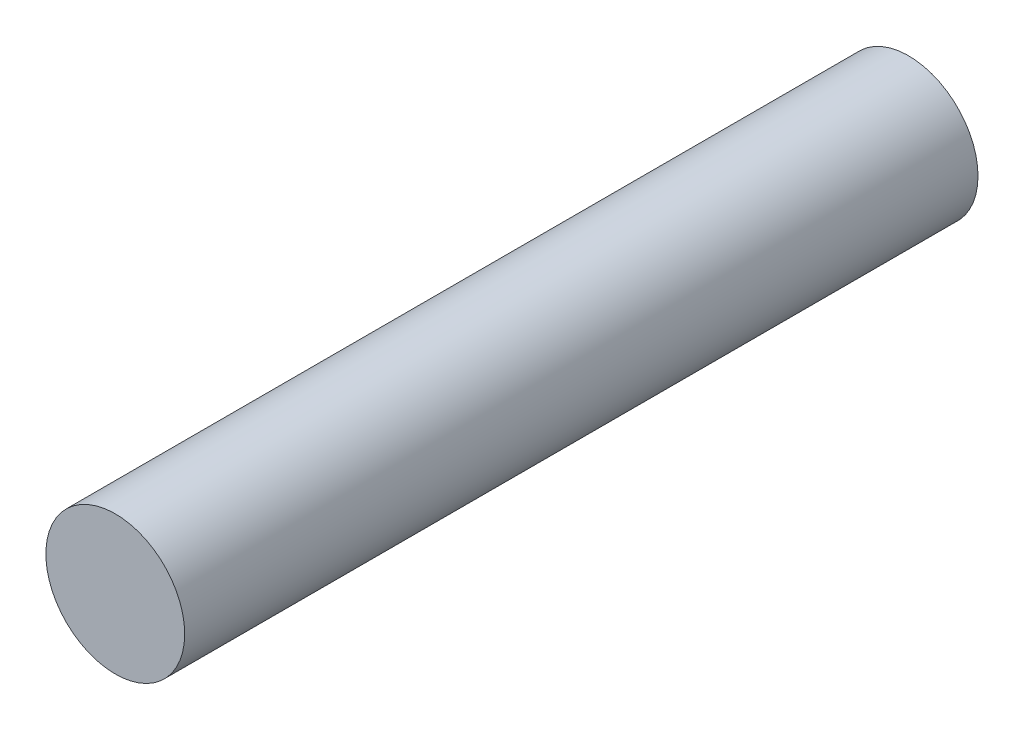
from build123d import *

# Parameters (mm, degrees)
SKETCH_1_R      = 70
EXTRUDE_1_DEPTH = 800


with BuildPart() as part:
    # 草图1 → 凸台-拉伸1 (new body)
    with BuildSketch(Plane.XY):
        Circle(SKETCH_1_R)
    extrude(amount=EXTRUDE_1_DEPTH)


solid = part.part
